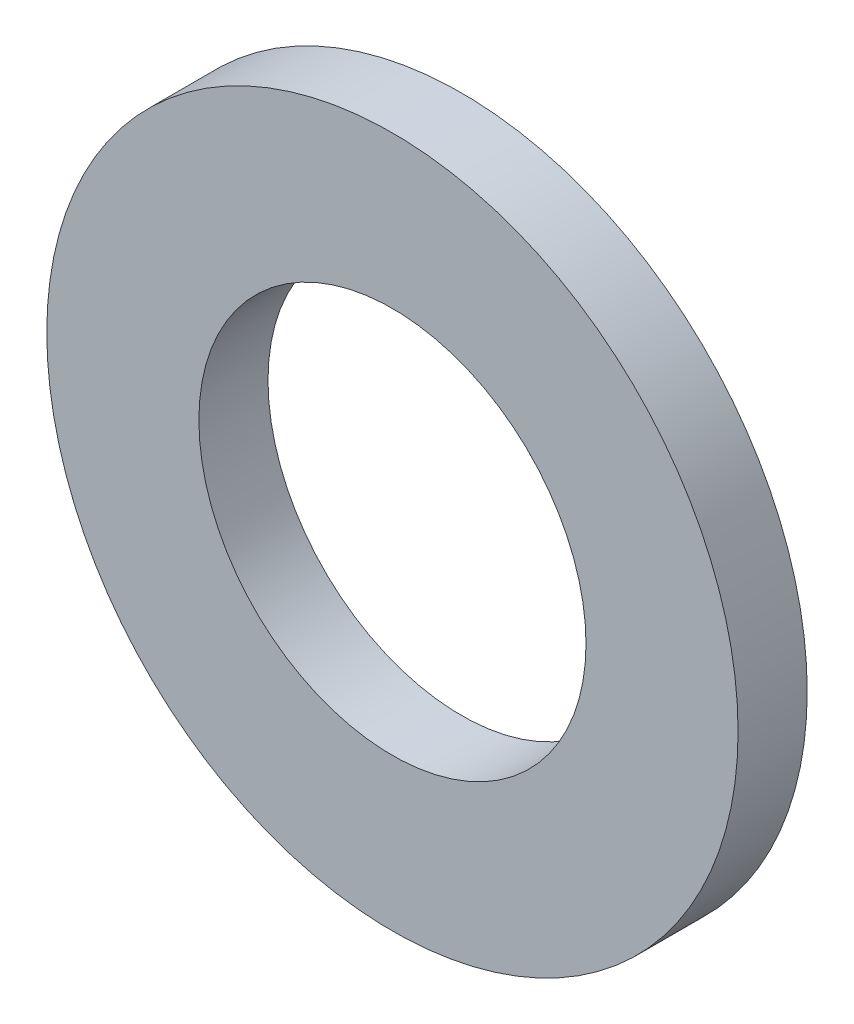
from build123d import *

# Parameters (mm, degrees)
SKETCH_1_R      = 5
SKETCH_1_R_2    = 2.8
EXTRUDE_1_DEPTH = 1


with BuildPart() as part:
    # 草圖1 → 填料-伸長1 (new body)
    with BuildSketch(Plane.XY):
        Circle(SKETCH_1_R)
        Circle(SKETCH_1_R_2, mode=Mode.SUBTRACT)
    extrude(amount=EXTRUDE_1_DEPTH)


solid = part.part
